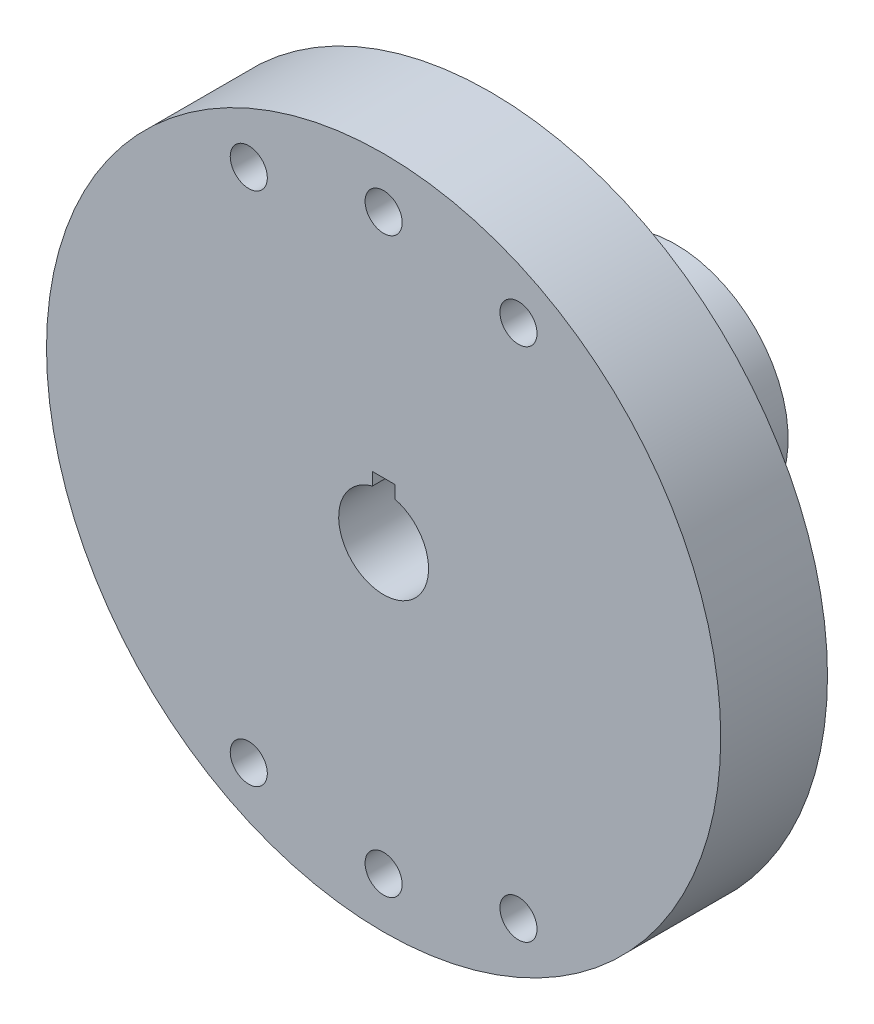
from build123d import *

# Parameters (mm, degrees)
SKETCH1_W                  = 30
SKETCH1_H                  = 9.5
CUT_EXTRUDE1_DEPTH         = 3.5
SKETCH3_R                  = 17.4
BOSS_EXTRUDE1_DEPTH        = 4
SKETCH4_R                  = 10
BOSS_EXTRUDE2_DEPTH        = 16
CUT_EXTRUDE2_DEPTH         = 50.759421218
SKETCH6_W                  = 4
SKETCH6_H                  = 26
F_4_CLEARANCE_HOLE1_D      = 3.3
F_2_CLEARANCE_HOLE1_D      = 2.5
F_2_CLEARANCE_HOLE1_DEPTH  = 12
F_2_CLEARANCE_HOLE2_REACH  = 54.582
F_2_CLEARANCE_HOLE2_BORE_R = 1.25
F_2_CLEARANCE_HOLE3_D      = 2.5
F_2_CLEARANCE_HOLE3_DEPTH  = 40
FILLET1_R                  = 3


with BuildPart() as part:
    # Sketch1 → Revolve1 (revolve)
    with BuildSketch(Plane.XZ, mode=Mode.PRIVATE) as revolve1_sk:
        with Locations((15, 5.25)):
            Rectangle(SKETCH1_W, SKETCH1_H)
    revolve(revolve1_sk.sketch.rotate(Axis((0, 0, 10), (0, 0, -1)), 180), axis=Axis((0, 0, 10), (0, 0, -1)))

    # Sketch2 → Cut-Extrude1 (cut)
    with BuildSketch(Plane(origin=(0, 0, 0.5), x_dir=(-1, 0, 0), z_dir=(0, 0, -1))):
        with BuildLine():
            ThreePointArc((1.901854596, -26.932934283), (6.318658968, -26.250229501), (10.562335147, -24.848281153))
            ThreePointArc((10.562335147, -24.848281153), (13.103370267, -25.060195635), (14.379253383, -22.852506912))
            ThreePointArc((14.379253383, -22.852506912), (27, 0), (14.379253383, 22.852506912))
            ThreePointArc((14.379253383, 22.852506912), (13.103370267, 25.060195635), (10.562335147, 24.848281153))
            ThreePointArc((10.562335147, 24.848281153), (6.318658968, 26.250229501), (1.901854596, 26.932934283))
            ThreePointArc((1.901854596, 26.932934283), (0, 27.88125), (-1.901854596, 26.932934283))
            ThreePointArc((-1.901854596, 26.932934283), (-6.318658968, 26.250229501), (-10.562335147, 24.848281153))
            ThreePointArc((-10.562335147, 24.848281153), (-13.103370267, 25.060195635), (-14.379253383, 22.852506912))
            ThreePointArc((-14.379253383, 22.852506912), (-27, 0), (-14.379253383, -22.852506912))
            ThreePointArc((-14.379253383, -22.852506912), (-13.103370267, -25.060195635), (-10.562335147, -24.848281153))
            ThreePointArc((-10.562335147, -24.848281153), (-6.318658968, -26.250229501), (-1.901854596, -26.932934283))
            ThreePointArc((-1.901854596, -26.932934283), (0, -27.88125), (1.901854596, -26.932934283))
        make_face()
    extrude(amount=-CUT_EXTRUDE1_DEPTH, mode=Mode.SUBTRACT)

    # Sketch3 → Boss-Extrude1 (add)
    with BuildSketch(Plane(origin=(0, 0, 4), x_dir=(-1, 0, 0), z_dir=(0, 0, -1))):
        Circle(SKETCH3_R)
    extrude(amount=BOSS_EXTRUDE1_DEPTH)

    # Sketch4 → Boss-Extrude2 (add)
    with BuildSketch(Plane(origin=(0, 0, 0), x_dir=(-1, 0, 0), z_dir=(0, 0, -1))):
        Circle(SKETCH4_R)
    extrude(amount=BOSS_EXTRUDE2_DEPTH)

    # Sketch5 → Cut-Extrude2 (cut, through all)
    with BuildSketch(Plane.XY.offset(10)):
        with BuildLine():
            Line((1, 5), (-1, 5))
            Line((-1, 5), (-1, 3.872983346))
            ThreePointArc((-1, 3.872983346), (0, 4), (1, 3.872983346))
            Line((1, 3.872983346), (1, 5))
        make_face()
    extrude(amount=-CUT_EXTRUDE2_DEPTH, mode=Mode.SUBTRACT)

    # Sketch6 → Cut-Revolve1 (revolve, cut)
    with BuildSketch(Plane.XZ):
        with Locations((2, -3)):
            Rectangle(SKETCH6_W, SKETCH6_H)
    revolve(axis=Axis((0, 0, 10), (0, 0, -1)), mode=Mode.SUBTRACT)

    # #4 Clearance Hole1 (through all)
    with Locations(Plane(origin=(0, 0, 4), x_dir=(-1, 0, 0), z_dir=(0, 0, -1))):
        with Locations((12, -22.95), (0, -25.5), (-12, -22.95), (-12, 22.95), (0, 25.5), (12, 22.95)):
            Hole(F_4_CLEARANCE_HOLE1_D / 2)

    # #2 Clearance Hole1
    with Locations(Plane(origin=(0, 0, -16), x_dir=(-1, 0, 0), z_dir=(0, 0, -1))):
        with Locations((-5.055813485, -5.055813485), (5.055813485, -5.055813485), (5.055813485, 5.055813485), (-5.055813485, 5.055813485)):
            Hole(F_2_CLEARANCE_HOLE1_D / 2, depth=F_2_CLEARANCE_HOLE1_DEPTH)

    # #2 Clearance Hole2 bore (on position points) → #2 Clearance Hole2 (cut, up to next)
    with BuildSketch(Plane(origin=(0, -10, -6.276306458), x_dir=(-1, 0, 0), z_dir=(0, -1, 0)), mode=Mode.PRIVATE) as f_2_clearance_hole2_sk1:
        Circle(F_2_CLEARANCE_HOLE2_BORE_R)
    f_2_clearance_hole2_tool1 = extrude(f_2_clearance_hole2_sk1.sketch, amount=-F_2_CLEARANCE_HOLE2_REACH, mode=Mode.PRIVATE) & part.part
    add(f_2_clearance_hole2_tool1.solids().sort_by_distance((0, -10, -6.276306))[0], mode=Mode.SUBTRACT)

    # #2 Clearance Hole3
    with Locations(Plane(origin=(0, 10, -6.276306458), x_dir=(1, 0, 0), z_dir=(0, 1, 0))):
        with Locations((0, 0)):
            Hole(F_2_CLEARANCE_HOLE3_D / 2, depth=F_2_CLEARANCE_HOLE3_DEPTH)

    # Fillet1
    fillet1_edges = [part.edges().sort_by_distance(p)[0] for p in [
        (10, 0, 0),
    ]]
    fillet(fillet1_edges, radius=FILLET1_R)


solid = part.part
